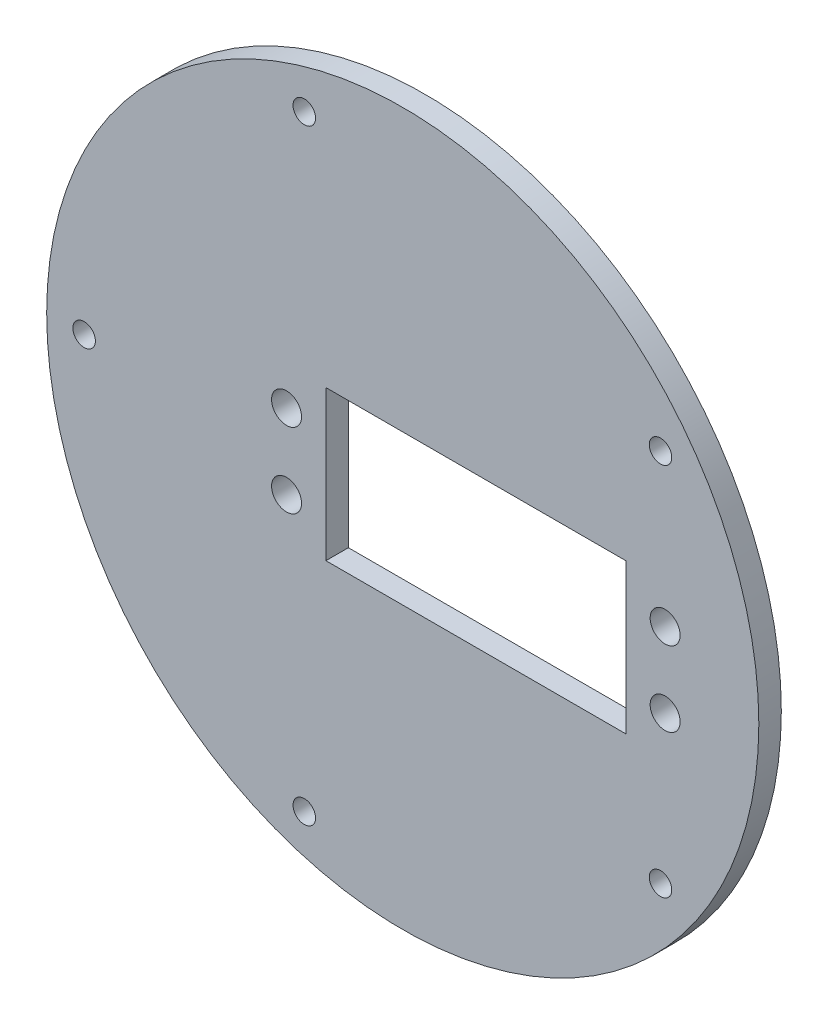
from build123d import *

# Parameters (mm, degrees)
CROQUIS1_R              = 47.5
SALIENTE_EXTRUIR1_DEPTH = 3
CROQUIS3_R              = 2
CROQUIS3_W              = 40
CROQUIS3_H              = 20
CORTAR_EXTRUIR1_DEPTH   = 4
CROQUIS4_R              = 1.5
CORTAR_EXTRUIR2_DEPTH   = 4


with BuildPart() as part:
    # Croquis1 → Saliente-Extruir1 (new body)
    with BuildSketch(Plane.XY):
        Circle(CROQUIS1_R)
    extrude(amount=SALIENTE_EXTRUIR1_DEPTH)

    # Croquis3 → Cortar-Extruir1 (cut, through all)
    with BuildSketch(Plane.XY.offset(3)):
        with Locations((35, -5)):
            Circle(CROQUIS3_R)
        with Locations((35, 5)):
            Circle(CROQUIS3_R)
        with Locations((-15.5, -5)):
            Circle(CROQUIS3_R)
        with Locations((-15.5, 5)):
            Circle(CROQUIS3_R)
        with Locations((9.75, 0)):
            Rectangle(CROQUIS3_W, CROQUIS3_H)
    extrude(amount=-CORTAR_EXTRUIR1_DEPTH, mode=Mode.SUBTRACT)

    # Croquis4 → Cortar-Extruir2 (cut, through all)
    with BuildSketch(Plane.XY.offset(3)):
        with Locations((-42.5, 0)):
            Circle(CROQUIS4_R)
        with Locations((-13.133222261, 40.419901943)):
            Circle(CROQUIS4_R)
        with Locations((34.383222261, 24.980873222)):
            Circle(CROQUIS4_R)
        with Locations((34.383222261, -24.980873222)):
            Circle(CROQUIS4_R)
        with Locations((-13.133222261, -40.419901943)):
            Circle(CROQUIS4_R)
    extrude(amount=-CORTAR_EXTRUIR2_DEPTH, mode=Mode.SUBTRACT)


solid = part.part
